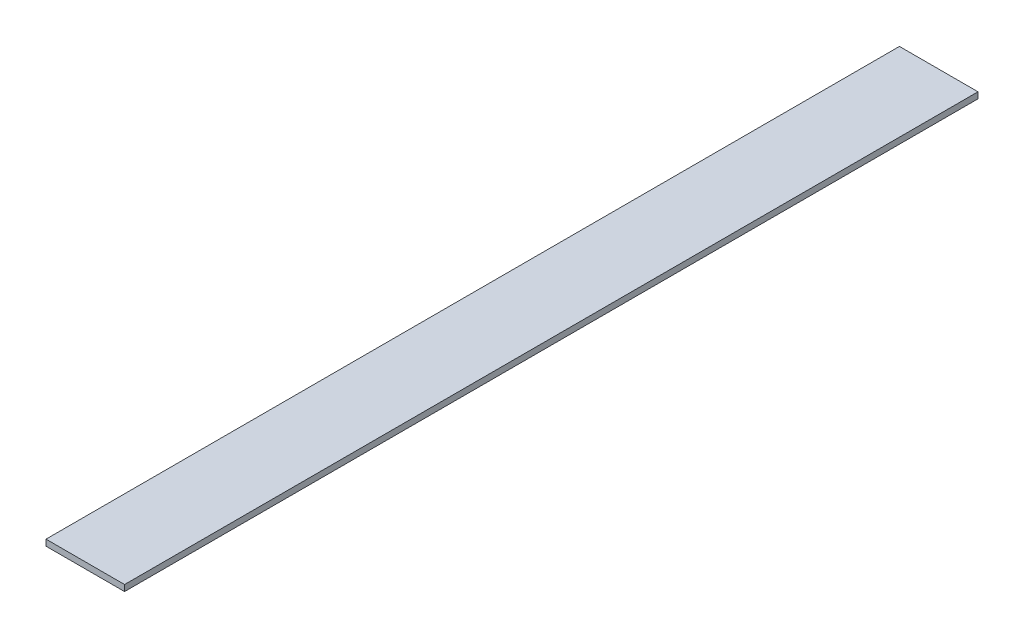
from build123d import *

# Parameters (mm, degrees)
SKETCH1_W           = 40.64
SKETCH1_H           = 3.175
BOSS_EXTRUDE1_DEPTH = 441.452


with BuildPart() as part:
    # Sketch1 → Boss-Extrude1 (new body)
    with BuildSketch(Plane.XY):
        with Locations((20.32, 1.5875)):
            Rectangle(SKETCH1_W, SKETCH1_H)
    extrude(amount=BOSS_EXTRUDE1_DEPTH)


solid = part.part
